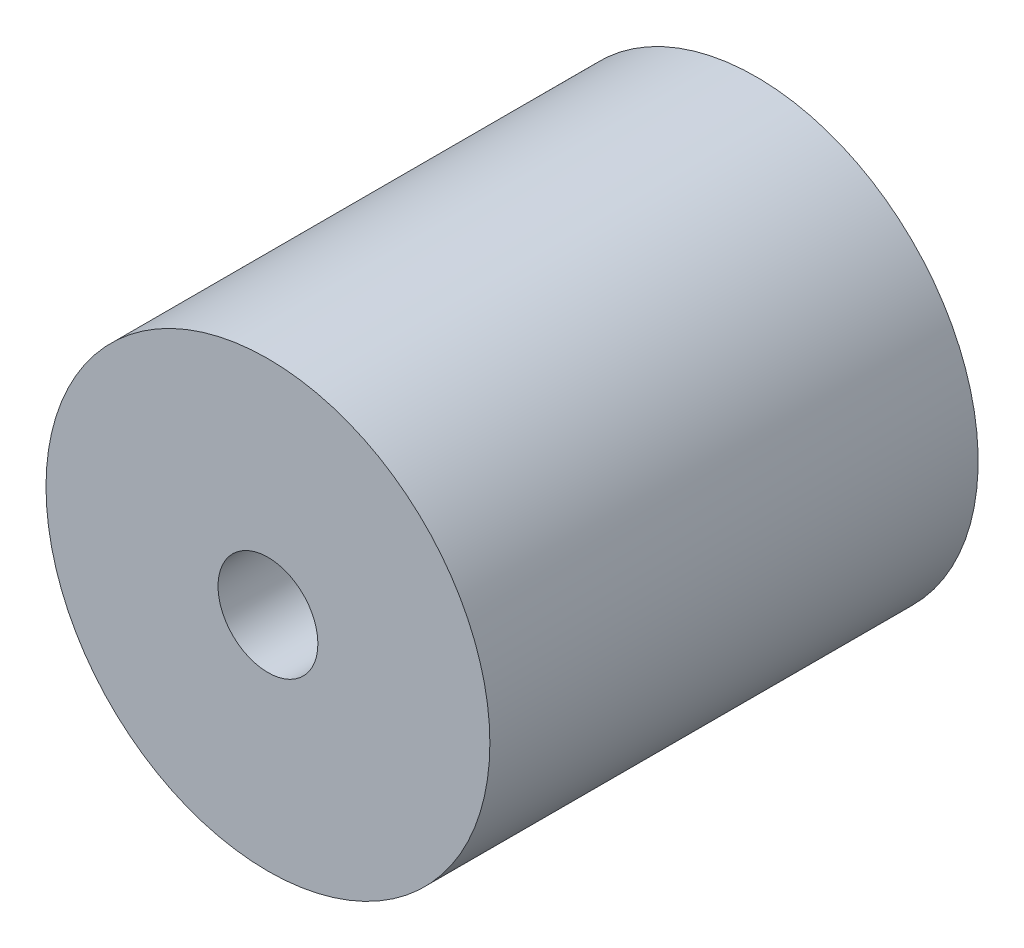
from build123d import *

# Parameters (mm, degrees)
ESBO_O1_R                = 10
ESBO_O1_R_2              = 2.25
RESSALTO_EXTRUS_O1_DEPTH = 15
ESBO_O2_R                = 2
CORTE_EXTRUS_O1_DEPTH    = 10
ESBO_O3_R                = 10
ESBO_O3_R_2              = 0.547725274
ESBO_O3_R_3              = 3.7
RESSALTO_EXTRUS_O2_DEPTH = 7


with BuildPart() as part:
    # Esboço1 → Ressalto-extrusão1 (new body)
    with BuildSketch(Plane.XY):
        Circle(ESBO_O1_R)
        Circle(ESBO_O1_R_2, mode=Mode.SUBTRACT)
    extrude(amount=RESSALTO_EXTRUS_O1_DEPTH)

    # Esboço2 → Corte-extrusão1 (cut)
    with BuildSketch(Plane(origin=(0, 0, 0), x_dir=(0, 0, -1), z_dir=(1, 0, 0))):
        with Locations((-7.5, 0)):
            Circle(ESBO_O2_R)
    extrude(amount=-CORTE_EXTRUS_O1_DEPTH, mode=Mode.SUBTRACT)

    # Esboço3 → Ressalto-extrusão2 (add)
    with BuildSketch(Plane(origin=(0, 0, 0), x_dir=(-1, 0, 0), z_dir=(0, 0, -1))):
        Circle(ESBO_O3_R)
        with Locations((0, 7.1)):
            Circle(ESBO_O3_R_2, mode=Mode.SUBTRACT)
        with Locations((7.1, 0)):
            Circle(ESBO_O3_R_2, mode=Mode.SUBTRACT)
        with Locations((0, -7.1)):
            Circle(ESBO_O3_R_2, mode=Mode.SUBTRACT)
        with Locations((-7.1, 0)):
            Circle(ESBO_O3_R_2, mode=Mode.SUBTRACT)
        Circle(ESBO_O3_R_3, mode=Mode.SUBTRACT)
    extrude(amount=RESSALTO_EXTRUS_O2_DEPTH)


solid = part.part
